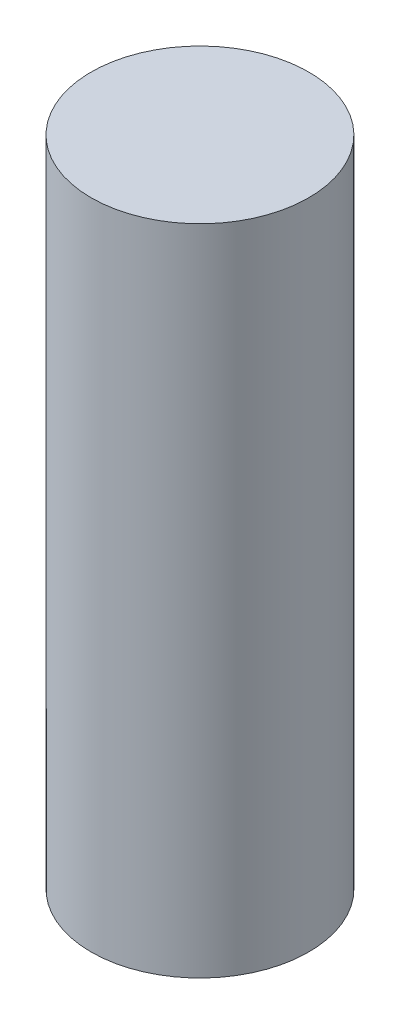
from build123d import *

# Parameters (mm, degrees)
SKIZZE1_R                       = 1
AUFSATZ_LINEAR_AUSTRAGEN1_DEPTH = 6


with BuildPart() as part:
    # Skizze1 → Aufsatz-Linear austragen1 (new body)
    with BuildSketch(Plane(origin=(0, 0, 0), x_dir=(1, 0, 0), z_dir=(0, 1, 0))):
        Circle(SKIZZE1_R)
    extrude(amount=AUFSATZ_LINEAR_AUSTRAGEN1_DEPTH)


solid = part.part
